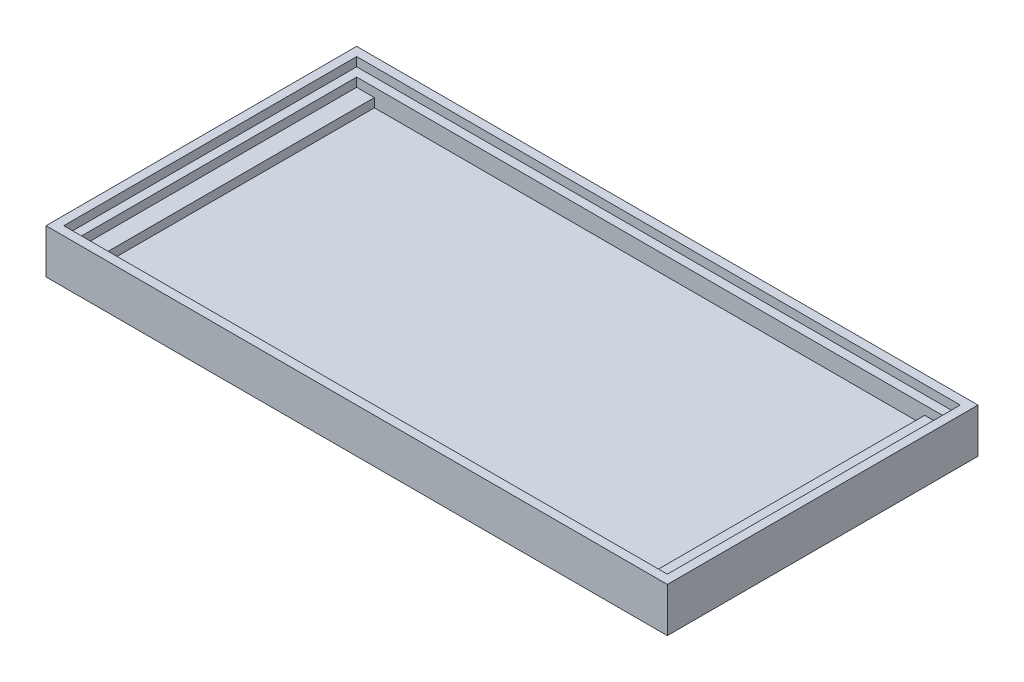
from build123d import *

# Parameters (mm, degrees)
SKETCH1_W           = 70
SKETCH1_H           = 35
BOSS_EXTRUDE1_DEPTH = 2
SKETCH2_W           = 70
SKETCH2_H           = 35
SKETCH2_W_2         = 66
SKETCH2_H_2         = 31
BOSS_EXTRUDE2_DEPTH = 2
SKETCH3_W           = 2
SKETCH3_H           = 31
BOSS_EXTRUDE3_DEPTH = 1
SKETCH4_W           = 70
SKETCH4_H           = 35
SKETCH4_W_2         = 68
SKETCH4_H_2         = 33
BOSS_EXTRUDE4_DEPTH = 1


with BuildPart() as part:
    # Sketch1 → Boss-Extrude1 (new body)
    with BuildSketch(Plane(origin=(0, 0, 0), x_dir=(1, 0, 0), z_dir=(0, 1, 0))):
        with Locations((33, 15.5)):
            Rectangle(SKETCH1_W, SKETCH1_H)
    extrude(amount=BOSS_EXTRUDE1_DEPTH)

    # Sketch2 → Boss-Extrude2 (add)
    with BuildSketch(Plane(origin=(0, 2, 0), x_dir=(1, 0, 0), z_dir=(0, 1, 0))):
        with Locations((33, 15.5)):
            Rectangle(SKETCH2_W, SKETCH2_H)
        with Locations((33, 15.5)):
            Rectangle(SKETCH2_W_2, SKETCH2_H_2, mode=Mode.SUBTRACT)
    extrude(amount=BOSS_EXTRUDE2_DEPTH)

    # Sketch3 → Boss-Extrude3 (add)
    with BuildSketch(Plane(origin=(0, 2, 0), x_dir=(1, 0, 0), z_dir=(0, 1, 0))):
        with Locations((1, 15.5)):
            Rectangle(SKETCH3_W, SKETCH3_H)
        with Locations((65, 15.5)):
            Rectangle(SKETCH3_W, SKETCH3_H)
    extrude(amount=BOSS_EXTRUDE3_DEPTH)

    # Sketch4 → Boss-Extrude4 (add)
    with BuildSketch(Plane(origin=(0, 4, 0), x_dir=(1, 0, 0), z_dir=(0, 1, 0))):
        with Locations((33, 15.5)):
            Rectangle(SKETCH4_W, SKETCH4_H)
        with Locations((33, 15.5)):
            Rectangle(SKETCH4_W_2, SKETCH4_H_2, mode=Mode.SUBTRACT)
    extrude(amount=BOSS_EXTRUDE4_DEPTH)


solid = part.part
